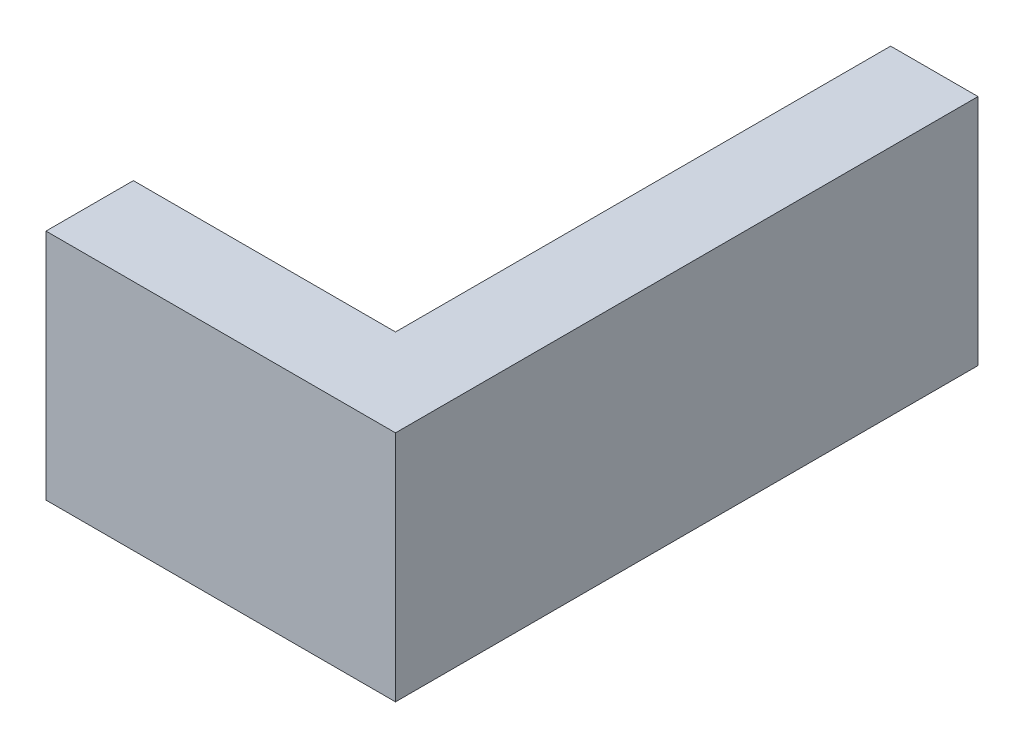
from build123d import *

# Parameters (mm, degrees)
SKETCH1_W           = 19.05
SKETCH1_H           = 107.95
SKETCH1_W_2         = 76.2
SKETCH1_H_2         = 19.05
BOSS_EXTRUDE1_DEPTH = 25.4


with BuildPart() as part:
    # Sketch1 → Boss-Extrude1 (new body, symmetric)
    with BuildSketch(Plane(origin=(0, 0, 0), x_dir=(1, 0, 0), z_dir=(0, 1, 0))):
        with Locations((66.675, 73.025)):
            Rectangle(SKETCH1_W, SKETCH1_H)
        with Locations((38.1, 9.525)):
            Rectangle(SKETCH1_W_2, SKETCH1_H_2)
    extrude(amount=BOSS_EXTRUDE1_DEPTH, both=True)


solid = part.part
